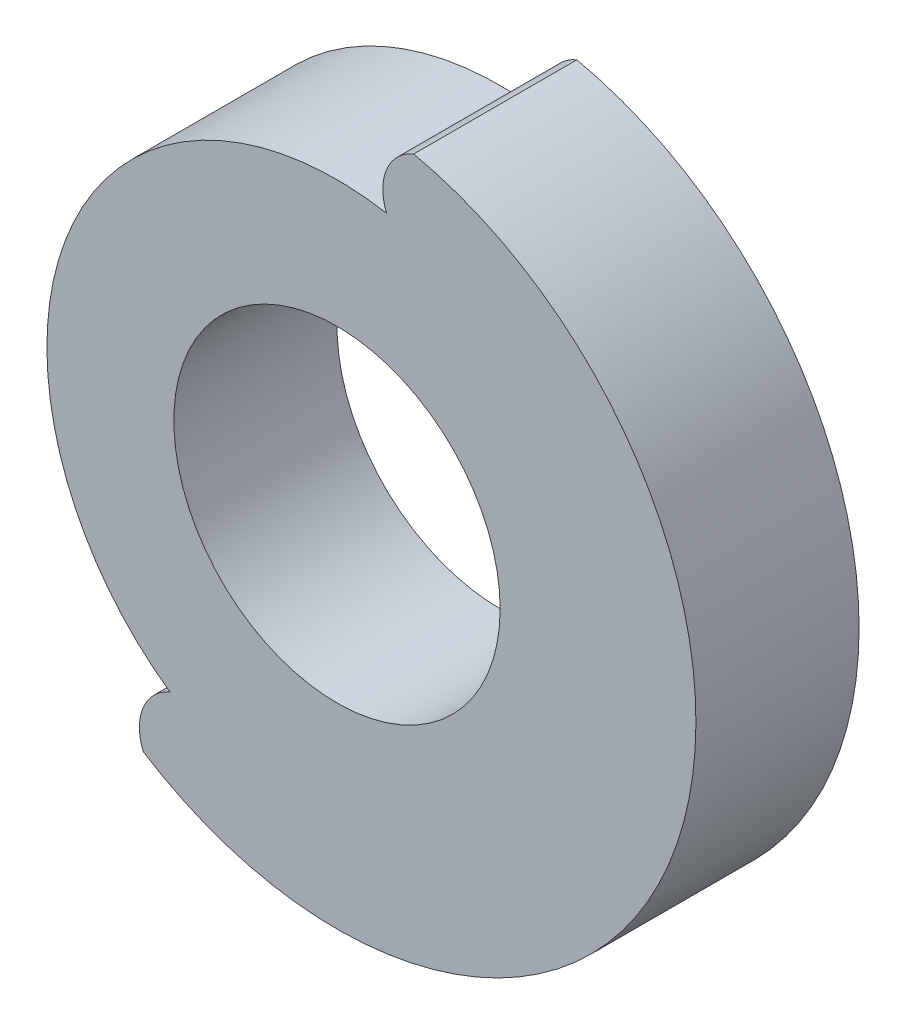
from build123d import *

# Parameters (mm, degrees)
SKETCH1_R           = 13.2
SKETCH1_R_2         = 6
BOSS_EXTRUDE1_DEPTH = 6
CUT_EXTRUDE1_DEPTH  = 7
CIRPATTERN2_COUNT   = 10
CIRPATTERN2_ANGLE   = 135


with BuildPart() as part:
    # Sketch1 → Boss-Extrude1 (new body)
    with BuildSketch(Plane.XY):
        Circle(SKETCH1_R)
        Circle(SKETCH1_R_2, mode=Mode.SUBTRACT)
    extrude(amount=BOSS_EXTRUDE1_DEPTH)

    # Sketch2 → Cut-Extrude1 (cut, through all)
    with BuildSketch(Plane.XY.offset(6)):
        with BuildLine():
            ThreePointArc((-2.819851171, 12.895287487), (0, 13.2), (2.819851171, 12.895287487))
            ThreePointArc((2.819851171, 12.895287487), (1.826256171, 11.910750525), (1.819851171, 10.512))
            ThreePointArc((1.819851171, 10.512), (0, 10.668364555), (-1.819851171, 10.512))
            ThreePointArc((-1.819851171, 10.512), (-1.826256171, 11.910750525), (-2.819851171, 12.895287487))
        make_face()
    cut_extrude1 = extrude(amount=-CUT_EXTRUDE1_DEPTH, mode=Mode.SUBTRACT)

    # CirPattern2: Cut-Extrude1 ×10 about axis
    cirpattern2_axis = Axis((0, 0, 6), (0, 0, 1))
    for i in range(1, CIRPATTERN2_COUNT):
        add(cut_extrude1.rotate(cirpattern2_axis, i * CIRPATTERN2_ANGLE / (CIRPATTERN2_COUNT - 1)), mode=Mode.SUBTRACT)


solid = part.part
